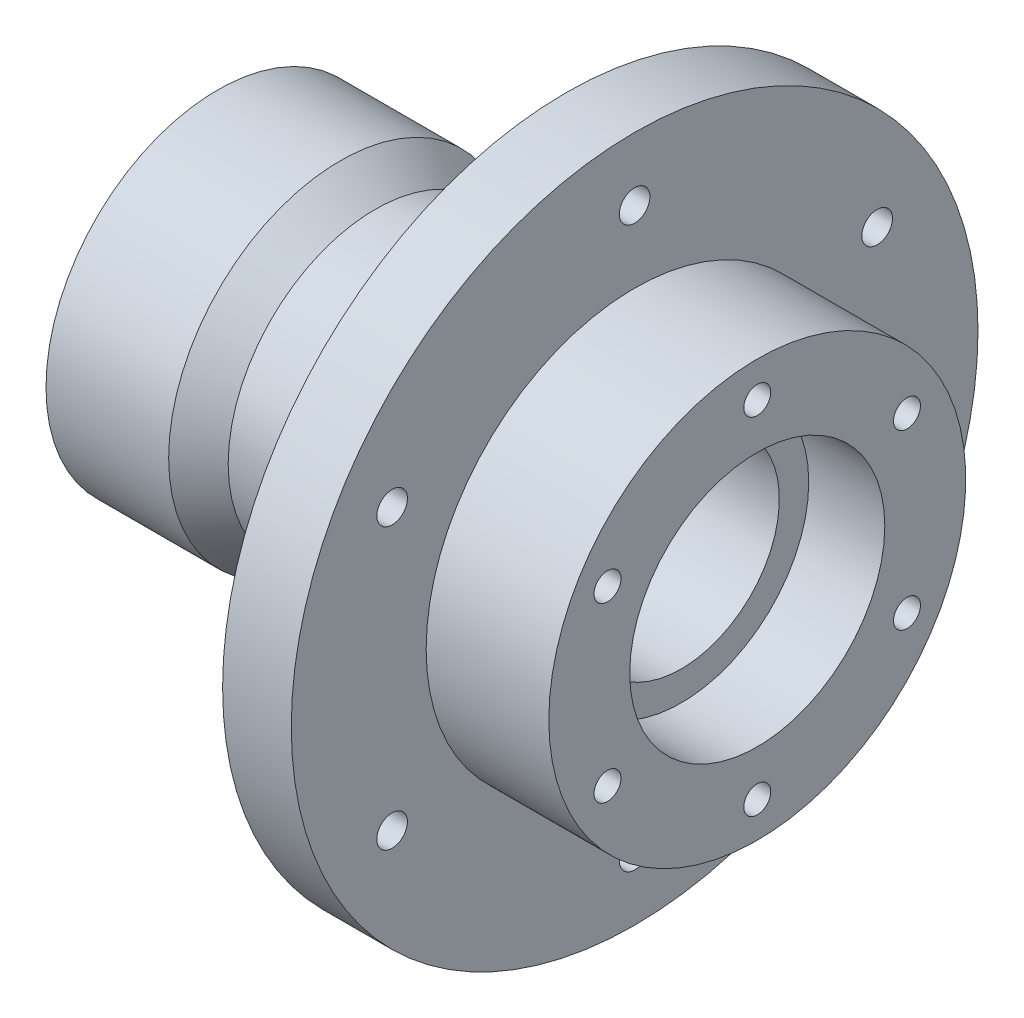
from build123d import *

# Parameters (mm, degrees)
SCHIZZO2_R                  = 3.125
TAGLIO_ESTRUSIONE1_DEPTH    = 14
RIPETIZIONECIRCOLARE1_COUNT = 6
RACCORDO1_R                 = 3


with BuildPart() as part:
    # Schizzo1 → Rivoluzione1 (revolve)
    with BuildSketch(Plane.XY):
        Polygon((-41.225471698, 23.5), (-27.225471698, 23.5), (-27.225471698, 20), (49.424528302, 20), (49.424528302, 26), (64.924528302, 26), (64.924528302, 42.5), (39.924528302, 42.5), (39.924528302, 70), (25.924528302, 70), (25.924528302, 30), (-12.934731664, 30), (-20.075471698, 35), (-45.075471698, 35), (-45.075471698, 23.5), (-43.075471698, 23.5), (-43.075471698, 24.75), (-41.225471698, 24.75), align=None)
    revolve(axis=Axis((0, 0, 0), (1, 0, 0)))

    # Schizzo2 → Taglio-Estrusione1 (cut)
    with BuildSketch(Plane(origin=(39.924528302, 0, 0), x_dir=(0, 0, -1), z_dir=(1, 0, 0))):
        with Locations((0, 57.09)):
            Circle(SCHIZZO2_R)
    taglio_estrusione1 = extrude(amount=-TAGLIO_ESTRUSIONE1_DEPTH, mode=Mode.SUBTRACT)

    # Schizzo5 → Foro per Vite M5-1 (revolve, cut)
    with BuildSketch(Plane(origin=(64.924528302, 35.25, 0), x_dir=(0, 0, -1), z_dir=(0, 1, 0))):
        Polygon((0, 0), (0, 12), (2.75, 10.347633298), (2.75, 0), align=None)
    foro_per_vite_m5_1 = revolve(axis=Axis((71.274528302, 35.25, 0), (-1, 0, 0)), mode=Mode.SUBTRACT)

    # RipetizioneCircolare1: Taglio-Estrusione1, Foro per Vite M5-1 ×6 about axis
    ripetizionecircolare1_axis = Axis((0, 0, 0), (1, 0, 0))
    for i in range(1, RIPETIZIONECIRCOLARE1_COUNT):
        add(taglio_estrusione1.rotate(ripetizionecircolare1_axis, i * 360 / RIPETIZIONECIRCOLARE1_COUNT), mode=Mode.SUBTRACT)
        add(foro_per_vite_m5_1.rotate(ripetizionecircolare1_axis, i * 360 / RIPETIZIONECIRCOLARE1_COUNT), mode=Mode.SUBTRACT)

    # Raccordo1
    raccordo1_edges = [part.edges().sort_by_distance(p)[0] for p in [
        (25.924528302, -30, 0),
    ]]
    fillet(raccordo1_edges, radius=RACCORDO1_R)


solid = part.part
